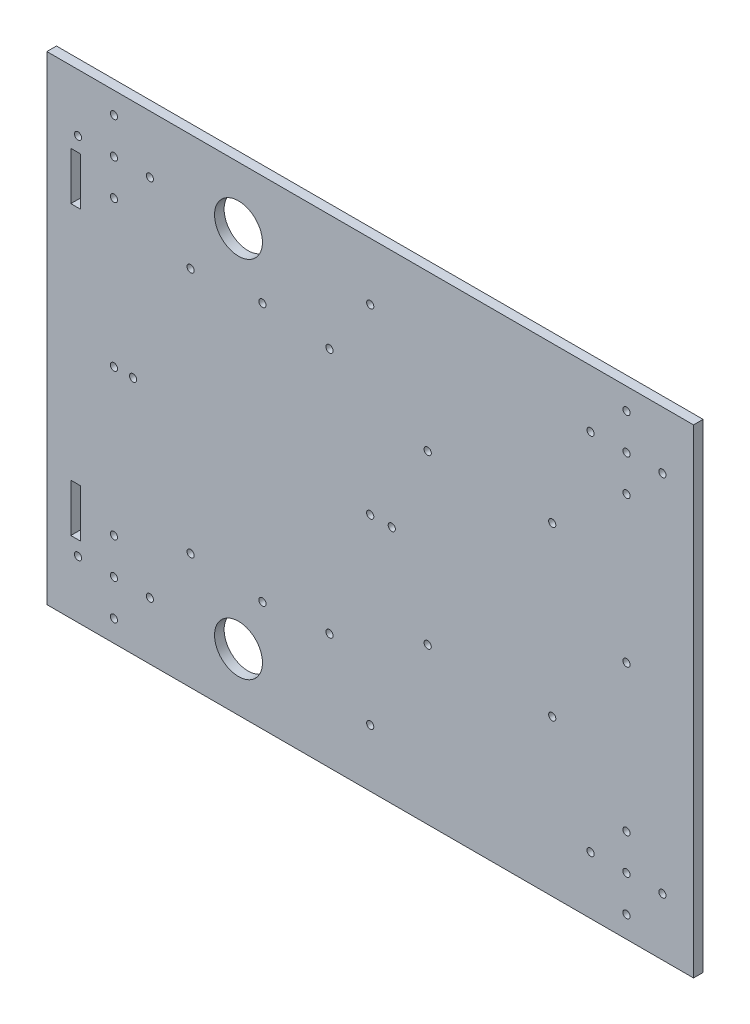
from build123d import *

# Parameters (mm, degrees)
SKETCH1_W           = 270
SKETCH1_H           = 200
SKETCH1_R           = 1.5
SKETCH1_R_2         = 10
SKETCH1_W_2         = 4
SKETCH1_H_2         = 20
BOSS_EXTRUDE1_DEPTH = 4


with BuildPart() as part:
    # Sketch1 → Boss-Extrude1 (new body)
    with BuildSketch(Plane.XY):
        with Locations((71.763348527, -16.133333333)):
            Rectangle(SKETCH1_W, SKETCH1_H)
        with Locations((-35.236651473, -92.133333333)):
            Circle(SKETCH1_R, mode=Mode.SUBTRACT)
        with Locations((-20.236651473, -92.133333333)):
            Circle(SKETCH1_R, mode=Mode.SUBTRACT)
        with Locations((-35.236651473, -107.133333333)):
            Circle(SKETCH1_R, mode=Mode.SUBTRACT)
        with Locations((-50.236651473, -92.133333333)):
            Circle(SKETCH1_R, mode=Mode.SUBTRACT)
        with Locations((-35.236651473, -77.133333333)):
            Circle(SKETCH1_R, mode=Mode.SUBTRACT)
        with Locations((71.763348527, -16.133333333)):
            Circle(SKETCH1_R, mode=Mode.SUBTRACT)
        with Locations((193.763348527, -92.133333333)):
            Circle(SKETCH1_R, mode=Mode.SUBTRACT)
        with Locations((178.763348527, -77.133333333)):
            Circle(SKETCH1_R, mode=Mode.SUBTRACT)
        with Locations((178.763348527, -92.133333333)):
            Circle(SKETCH1_R, mode=Mode.SUBTRACT)
        with Locations((178.763348527, -107.133333333)):
            Circle(SKETCH1_R, mode=Mode.SUBTRACT)
        with Locations((163.763348527, -92.133333333)):
            Circle(SKETCH1_R, mode=Mode.SUBTRACT)
        with Locations((193.763348527, 59.866666667)):
            Circle(SKETCH1_R, mode=Mode.SUBTRACT)
        with Locations((178.763348527, 74.866666667)):
            Circle(SKETCH1_R, mode=Mode.SUBTRACT)
        with Locations((178.763348527, 59.866666667)):
            Circle(SKETCH1_R, mode=Mode.SUBTRACT)
        with Locations((178.763348527, 44.866666667)):
            Circle(SKETCH1_R, mode=Mode.SUBTRACT)
        with Locations((163.763348527, 59.866666667)):
            Circle(SKETCH1_R, mode=Mode.SUBTRACT)
        with Locations((-20.236651473, 59.866666667)):
            Circle(SKETCH1_R, mode=Mode.SUBTRACT)
        with Locations((-35.236651473, 74.866666667)):
            Circle(SKETCH1_R, mode=Mode.SUBTRACT)
        with Locations((-35.236651473, 59.866666667)):
            Circle(SKETCH1_R, mode=Mode.SUBTRACT)
        with Locations((-35.236651473, 44.866666667)):
            Circle(SKETCH1_R, mode=Mode.SUBTRACT)
        with Locations((-50.236651473, 59.866666667)):
            Circle(SKETCH1_R, mode=Mode.SUBTRACT)
        with Locations((178.763348527, -16.133333333)):
            Circle(SKETCH1_R, mode=Mode.SUBTRACT)
        with Locations((95.763348527, 18.866666667)):
            Circle(SKETCH1_R, mode=Mode.SUBTRACT)
        with Locations((71.763348527, 59.866666667)):
            Circle(SKETCH1_R, mode=Mode.SUBTRACT)
        with Locations((16.763348527, 59.866666667)):
            Circle(SKETCH1_R_2, mode=Mode.SUBTRACT)
        with Locations((16.763348527, -92.133333333)):
            Circle(SKETCH1_R_2, mode=Mode.SUBTRACT)
        with Locations((-35.236651473, -16.133333333)):
            Circle(SKETCH1_R, mode=Mode.SUBTRACT)
        with Locations((71.763348527, -92.133333333)):
            Circle(SKETCH1_R, mode=Mode.SUBTRACT)
        with Locations((26.763348527, -70.133333333)):
            Circle(SKETCH1_R, mode=Mode.SUBTRACT)
        with Locations((-27.236651473, -16.133333333)):
            Circle(SKETCH1_R, mode=Mode.SUBTRACT)
        with Locations((26.763348527, 37.866666667)):
            Circle(SKETCH1_R, mode=Mode.SUBTRACT)
        with Locations((80.763348527, -16.133333333)):
            Circle(SKETCH1_R, mode=Mode.SUBTRACT)
        with Locations((147.763348527, 18.866666667)):
            Circle(SKETCH1_R, mode=Mode.SUBTRACT)
        with Locations((147.763348527, -51.133333333)):
            Circle(SKETCH1_R, mode=Mode.SUBTRACT)
        with Locations((95.763348527, -51.133333333)):
            Circle(SKETCH1_R, mode=Mode.SUBTRACT)
        with Locations((-3.236651473, 35.366666667)):
            Circle(SKETCH1_R, mode=Mode.SUBTRACT)
        with Locations((54.763348527, 35.366666667)):
            Circle(SKETCH1_R, mode=Mode.SUBTRACT)
        with Locations((54.763348527, -67.633333333)):
            Circle(SKETCH1_R, mode=Mode.SUBTRACT)
        with Locations((-3.236651473, -67.633333333)):
            Circle(SKETCH1_R, mode=Mode.SUBTRACT)
        with Locations((-51.236651473, 43.866666667)):
            Rectangle(SKETCH1_W_2, SKETCH1_H_2, mode=Mode.SUBTRACT)
        with Locations((-51.236651473, -76.133333333)):
            Rectangle(SKETCH1_W_2, SKETCH1_H_2, mode=Mode.SUBTRACT)
    extrude(amount=BOSS_EXTRUDE1_DEPTH)


solid = part.part
